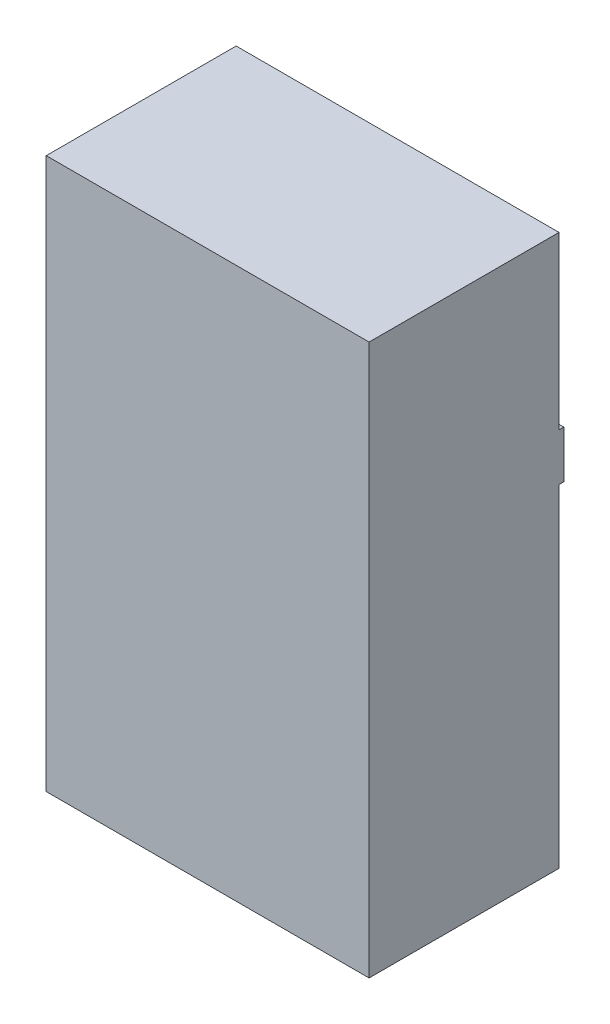
from build123d import *

# Parameters (mm, degrees)
SKETCH1_W           = 34
SKETCH1_H           = 58
BOSS_EXTRUDE1_DEPTH = 20
CUT_EXTRUDE1_DEPTH  = 5
SKETCH3_W           = 34
SKETCH3_H           = 5
BOSS_EXTRUDE2_DEPTH = 0.5


with BuildPart() as part:
    # Sketch1 → Boss-Extrude1 (new body)
    with BuildSketch(Plane.XY):
        with Locations((17, 29)):
            Rectangle(SKETCH1_W, SKETCH1_H)
    extrude(amount=BOSS_EXTRUDE1_DEPTH)

    # Sketch2 → Cut-Extrude1 (cut)
    with BuildSketch(Plane.XZ):
        Polygon((10.390351515, 13.754782864), (11.113909207, 13.754782864), (10.625928438, 10.254782864), (10.309722508, 10.254782864), (10.753532604, 13.4406803), (10.264850713, 13.4406803), align=None)
        with BuildLine():
            Line((12.643055841, 12.722731582), (12.328953277, 12.722731582))
            add(Edge.make_bspline(
                [(12.328953277, 12.722731582), (12.332011924, 12.766042879), (12.337989787, 12.850691115), (12.358167334, 12.973391915), (12.38473027, 13.089111099), (12.421716538, 13.196550853), (12.465427205, 13.297118572), (12.519464545, 13.389163263), (12.580321699, 13.474701699), (12.649982028, 13.551793987), (12.726424632, 13.620540594), (12.808860156, 13.680550874), (12.89686882, 13.731071088), (12.990250158, 13.772981842), (13.089302552, 13.804913995), (13.193463165, 13.828253888), (13.303171395, 13.841506096), (13.37803021, 13.843503065), (13.416393181, 13.844526454)],
                knots=[0, 0, 0, 0, 0.000130192, 0.000254449, 0.000372639, 0.000485937, 0.000594855, 0.00070104, 0.000805528, 0.000909287, 0.001012056, 0.00111345, 0.001214589, 0.001315961, 0.001419947, 0.001526261, 0.001635748, 0.001750837, 0.001750837, 0.001750837, 0.001750837], degree=3))
            add(Edge.make_bspline(
                [(13.416393181, 13.844526454), (13.448906153, 13.843648264), (13.512984399, 13.841917481), (13.60708216, 13.830350128), (13.696762583, 13.808643874), (13.782595889, 13.780482818), (13.863701387, 13.742473226), (13.941565938, 13.697869564), (14.014307414, 13.643265009), (14.082803929, 13.582003961), (14.144738145, 13.514528381), (14.198867312, 13.442495662), (14.246182958, 13.367304996), (14.282695193, 13.286764028), (14.312886758, 13.203263703), (14.332671859, 13.115378808), (14.345953396, 13.023918959), (14.347431482, 12.961395984), (14.348184047, 12.929562512)],
                knots=[0, 0, 0, 0, 9.7547e-05, 0.00019225, 0.000283743, 0.000373981, 0.000462761, 0.000551988, 0.000642715, 0.000735061, 0.000827359, 0.000916963, 0.001005106, 0.00109325, 0.001181728, 0.001271013, 0.001363028, 0.001458473, 0.001458473, 0.001458473, 0.001458473], degree=3))
            add(Edge.make_bspline(
                [(14.348184047, 12.929562512), (14.346613841, 12.884331868), (14.343455892, 12.793365368), (14.315970845, 12.657801515), (14.272912565, 12.523039023), (14.22238461, 12.410326163), (14.167104056, 12.315527957), (14.111540247, 12.232493322), (14.041785515, 12.138659995), (13.957720144, 12.0341532), (13.860296079, 11.918137768), (13.749619382, 11.790224009), (13.623738516, 11.652376545), (13.53453459, 11.557355245), (13.487907604, 11.507687512)],
                knots=[0, 0, 0, 0, 0.000135578, 0.00027267, 0.000413248, 0.000559472, 0.000642088, 0.000742233, 0.000859043, 0.000992739, 0.001144539, 0.00131352, 0.001500142, 0.001704517, 0.001704517, 0.001704517, 0.001704517], degree=3))
            Line((13.487907604, 11.507687512), (12.624826675, 10.568885428))
            Line((12.624826675, 10.568885428), (14.168696867, 10.568885428))
            Line((14.168696867, 10.568885428), (14.128732925, 10.254782864))
            Line((14.128732925, 10.254782864), (11.925107124, 10.254782864))
            Line((11.925107124, 10.254782864), (13.098083886, 11.530123409))
            add(Edge.make_bspline(
                [(13.098083886, 11.530123409), (13.125448976, 11.560018602), (13.178841591, 11.618347756), (13.256567902, 11.703972762), (13.330537387, 11.78501513), (13.398946138, 11.863291923), (13.464227047, 11.936634642), (13.525390682, 12.00613654), (13.582039019, 12.071737586), (13.634127663, 12.133895929), (13.682297266, 12.191832911), (13.726593673, 12.245537403), (13.765930846, 12.295866761), (13.801727361, 12.341532729), (13.832599938, 12.384170538), (13.860081837, 12.422097962), (13.882372259, 12.456878075), (13.918860652, 12.513997939), (13.960546521, 12.598318519), (14.003136833, 12.710319869), (14.028741496, 12.821844905), (14.032325457, 12.896022412), (14.034081483, 12.932366999)],
                knots=[0, 0, 0, 0, 0.000121586, 0.000237228, 0.000346928, 0.000450744, 0.000549086, 0.000641491, 0.000728489, 0.000809103, 0.000884779, 0.000954533, 0.001017933, 0.001076412, 0.001128579, 0.001175851, 0.001216883, 0.001252482, 0.00137916, 0.001498066, 0.001611529, 0.001720528, 0.001720528, 0.001720528, 0.001720528], degree=3))
            add(Edge.make_bspline(
                [(14.034081483, 12.932366999), (14.033552936, 12.952960299), (14.032515271, 12.993389929), (14.024004689, 13.052916944), (14.009216133, 13.109748589), (13.988695048, 13.164246235), (13.962526126, 13.216341743), (13.931035635, 13.266488171), (13.892814102, 13.313443105), (13.849424769, 13.357365869), (13.80203737, 13.39767965), (13.751676031, 13.434102149), (13.697061627, 13.463168233), (13.640255282, 13.488124684), (13.579986502, 13.506860428), (13.517004194, 13.52121577), (13.450459254, 13.528660411), (13.405191016, 13.529827151), (13.382038213, 13.53042389)],
                knots=[0, 0, 0, 0, 6.1762e-05, 0.000121255, 0.000179923, 0.000237611, 0.000295618, 0.000354554, 0.000414887, 0.00047686, 0.000539524, 0.000601385, 0.000662881, 0.000724746, 0.000787276, 0.000851916, 0.000918272, 0.000987739, 0.000987739, 0.000987739, 0.000987739], degree=3))
            add(Edge.make_bspline(
                [(13.382038213, 13.53042389), (13.35629539, 13.529744602), (13.306019695, 13.528417954), (13.232347168, 13.51818883), (13.1619958, 13.502394102), (13.094914362, 13.479192584), (13.031851256, 13.448609106), (12.971519136, 13.412907362), (12.9151958, 13.369706972), (12.862892192, 13.320054233), (12.814931266, 13.264570759), (12.772956248, 13.203265323), (12.736027195, 13.136726994), (12.705375672, 13.064565023), (12.680858537, 12.986781375), (12.662135085, 12.903752889), (12.648444231, 12.815208051), (12.644883472, 12.754097698), (12.643055841, 12.722731582)],
                knots=[0, 0, 0, 0, 7.7203e-05, 0.000150777, 0.00022272, 0.000293231, 0.000363164, 0.000432664, 0.000503199, 0.000575608, 0.00064869, 0.000722787, 0.000798104, 0.000876633, 0.000957566, 0.001042437, 0.001131777, 0.001225988, 0.001225988, 0.001225988, 0.001225988], degree=3))
        make_face()
        with BuildLine():
            add(Edge.make_bspline(
                [(16.194237733, 13.844526454), (16.22679258, 13.843438163), (16.290907144, 13.841294847), (16.384817404, 13.824627884), (16.474846903, 13.797968941), (16.560625859, 13.760003033), (16.641992457, 13.710522767), (16.720308511, 13.651910723), (16.793139489, 13.580595994), (16.862565721, 13.500420549), (16.925779132, 13.409987219), (16.980318657, 13.309574436), (17.027652687, 13.200667729), (17.065138701, 13.082134966), (17.094426865, 12.955032471), (17.115266016, 12.818882238), (17.127969662, 12.673896166), (17.129466894, 12.574120477), (17.130235329, 12.522911871)],
                knots=[0, 0, 0, 0, 9.7617e-05, 0.00019225, 0.000285193, 0.000378735, 0.000472763, 0.000570361, 0.000671517, 0.000777907, 0.000888188, 0.001001779, 0.001120171, 0.001243895, 0.001374169, 0.001511111, 0.001656791, 0.001810394, 0.001810394, 0.001810394, 0.001810394], degree=3))
            add(Edge.make_bspline(
                [(17.130235329, 12.522911871), (17.129605829, 12.463298015), (17.128363109, 12.345611973), (17.117173997, 12.171405417), (17.101122729, 12.001682782), (17.076076243, 11.836874867), (17.04550083, 11.676528452), (17.007664064, 11.52090074), (16.962874658, 11.36991462), (16.911046255, 11.224801189), (16.854716569, 11.087431321), (16.796014434, 10.958851878), (16.733479046, 10.841411265), (16.669455014, 10.733258938), (16.600895439, 10.636664569), (16.531475276, 10.548792799), (16.457204507, 10.47308429), (16.381338111, 10.406573982), (16.302984776, 10.349822268), (16.22369347, 10.300296448), (16.142754126, 10.2591953), (16.061187818, 10.223891793), (15.977298484, 10.19834121), (15.892451055, 10.179506008), (15.806207536, 10.166622423), (15.748137069, 10.165569706), (15.718877156, 10.165039275)],
                knots=[0, 0, 0, 0, 0.00017882, 0.000353016, 0.00052352, 0.000690101, 0.000852906, 0.001013094, 0.001170372, 0.00132516, 0.001475149, 0.001615688, 0.001748985, 0.001874156, 0.001992421, 0.002104109, 0.002209718, 0.002310103, 0.002406446, 0.002499642, 0.002590263, 0.002678552, 0.002765925, 0.002852847, 0.002939211, 0.003026921, 0.003026921, 0.003026921, 0.003026921], degree=3))
            add(Edge.make_bspline(
                [(15.718877156, 10.165039275), (15.675730879, 10.166756436), (15.5911539, 10.170122481), (15.46837972, 10.197655498), (15.353442587, 10.242162018), (15.264517318, 10.293801549), (15.198714131, 10.344022462), (15.151326643, 10.386207699), (15.107300208, 10.433577884), (15.065196197, 10.484882808), (15.024916391, 10.540318964), (14.987923098, 10.601048502), (14.952890656, 10.666043225), (14.920633099, 10.735822624), (14.890808694, 10.810224784), (14.865843371, 10.890220015), (14.844893513, 10.97550989), (14.827556416, 11.065863361), (14.813421932, 11.161272118), (14.80372262, 11.261891103), (14.798226296, 11.367868375), (14.797350782, 11.440373385), (14.796901995, 11.477539275)],
                knots=[0, 0, 0, 0, 0.000129328, 0.000253514, 0.000375382, 0.000497918, 0.000560459, 0.000623517, 0.000687998, 0.000754249, 0.00082255, 0.000893377, 0.000967408, 0.001043946, 0.001123886, 0.001207705, 0.001295109, 0.001387236, 0.001483614, 0.001584354, 0.001690372, 0.00180187, 0.00180187, 0.00180187, 0.00180187], degree=3))
            add(Edge.make_bspline(
                [(14.796901995, 11.477539275), (14.79759839, 11.539485458), (14.798968414, 11.661352745), (14.809093343, 11.841194686), (14.824841716, 12.015031858), (14.84780652, 12.182824488), (14.878412066, 12.344301124), (14.913697827, 12.500332072), (14.956343306, 12.650427767), (15.006199694, 12.793641809), (15.060492311, 12.928776473), (15.11811316, 13.054973573), (15.178642732, 13.171401309), (15.243214832, 13.277398651), (15.310565797, 13.373495163), (15.381513666, 13.459165592), (15.455194139, 13.535591426), (15.532519945, 13.601636637), (15.61234644, 13.658060499), (15.692013761, 13.708692414), (15.773873964, 13.749725156), (15.85590411, 13.784489901), (15.939159511, 13.811472053), (16.023486332, 13.82998807), (16.108538297, 13.84289253), (16.165677956, 13.843981941), (16.194237733, 13.844526454)],
                knots=[0, 0, 0, 0, 0.00018583, 0.000365586, 0.00054021, 0.000709368, 0.00087342, 0.001033123, 0.00118914, 0.001341246, 0.001487846, 0.001625889, 0.001757291, 0.001881262, 0.001997978, 0.002109023, 0.002214632, 0.002316079, 0.002413558, 0.00250772, 0.002598966, 0.0026879, 0.002774817, 0.002861055, 0.002946724, 0.003032332, 0.003032332, 0.003032332, 0.003032332], degree=3))
        make_face()
        with BuildLine():
            add(Edge.make_bspline(
                [(16.170399591, 13.53042389), (16.151425115, 13.529703819), (16.113231413, 13.528254387), (16.055720665, 13.517715421), (15.997349907, 13.501775947), (15.938061749, 13.478151586), (15.878282007, 13.447929513), (15.817252732, 13.411798218), (15.755704036, 13.368846929), (15.693257646, 13.319418973), (15.632089219, 13.261663881), (15.573187301, 13.195560319), (15.516854379, 13.120798705), (15.463768715, 13.036798581), (15.412506566, 12.944198135), (15.364452141, 12.842411331), (15.318933546, 12.732164326), (15.276374026, 12.6137879), (15.237027962, 12.488362722), (15.203679435, 12.356016178), (15.17471115, 12.21807198), (15.152202779, 12.073819227), (15.132590445, 11.924065654), (15.12072041, 11.768188852), (15.11265247, 11.606631182), (15.111560665, 11.496947639), (15.111004559, 11.441080941)],
                knots=[0, 0, 0, 0, 5.6899e-05, 0.000114532, 0.000174918, 0.000238194, 0.000305607, 0.000375709, 0.000450782, 0.000530605, 0.000614426, 0.000702812, 0.000795922, 0.000894919, 0.001000677, 0.001113263, 0.0012324, 0.001358372, 0.00149054, 0.00162658, 0.00176766, 0.001913241, 0.00206447, 0.00222063, 0.002382072, 0.002549664, 0.002549664, 0.002549664, 0.002549664], degree=3))
            add(Edge.make_bspline(
                [(15.111004559, 11.441080941), (15.111469882, 11.401563813), (15.112368625, 11.325238736), (15.121315164, 11.214599766), (15.133684431, 11.111596883), (15.153696789, 11.016846753), (15.177792289, 10.929558383), (15.20868335, 10.850580621), (15.244325078, 10.778873991), (15.285899706, 10.715635091), (15.331519991, 10.66016609), (15.380195111, 10.612007183), (15.431548681, 10.571265811), (15.485053864, 10.537002164), (15.541651743, 10.510760322), (15.601151447, 10.492716147), (15.663021426, 10.480915009), (15.705267993, 10.479736581), (15.726589495, 10.479141839)],
                knots=[0, 0, 0, 0, 0.000118523, 0.00022892, 0.000332842, 0.000429508, 0.000519169, 0.00060419, 0.000683519, 0.000758971, 0.000830698, 0.00089862, 0.00096399, 0.001027013, 0.001088811, 0.001150462, 0.001213172, 0.001277071, 0.001277071, 0.001277071, 0.001277071], degree=3))
            add(Edge.make_bspline(
                [(15.726589495, 10.479141839), (15.748837782, 10.479768689), (15.793385922, 10.481023843), (15.859745617, 10.492744733), (15.925185875, 10.511905833), (15.98997704, 10.538034091), (16.05425105, 10.571403338), (16.118084334, 10.611912566), (16.180426777, 10.661139244), (16.242820616, 10.716036145), (16.303095616, 10.778612706), (16.360453466, 10.848020943), (16.414530677, 10.92396799), (16.464886594, 11.006433723), (16.512691449, 11.094765257), (16.556737309, 11.189657165), (16.597595775, 11.291028772), (16.621559861, 11.361497312), (16.633841098, 11.39761139)],
                knots=[0, 0, 0, 0, 6.6699e-05, 0.000133552, 0.000201449, 0.000270973, 0.000342782, 0.000418442, 0.000497398, 0.000580835, 0.000667607, 0.000757736, 0.000850732, 0.000947051, 0.001047436, 0.001151887, 0.00126073, 0.001375149, 0.001375149, 0.001375149, 0.001375149], degree=3))
            add(Edge.make_bspline(
                [(16.633841098, 11.39761139), (16.648493494, 11.444001362), (16.677915517, 11.537152465), (16.714957507, 11.679394988), (16.745358796, 11.824126187), (16.771969405, 11.970821931), (16.790896901, 12.120204892), (16.806124285, 12.271649505), (16.81448476, 12.425593931), (16.815580369, 12.528979148), (16.816132765, 12.58110498)],
                knots=[0, 0, 0, 0, 0.000145931, 0.00029303, 0.000440719, 0.000589532, 0.000740155, 0.000892312, 0.001046088, 0.001202463, 0.001202463, 0.001202463, 0.001202463], degree=3))
            add(Edge.make_bspline(
                [(16.816132765, 12.58110498), (16.815615735, 12.619447404), (16.814615018, 12.693659689), (16.806325895, 12.801417194), (16.791700495, 12.901663827), (16.771452649, 12.994725147), (16.74576626, 13.080439543), (16.714257193, 13.158694278), (16.677038522, 13.229684121), (16.63351841, 13.292638975), (16.585588184, 13.348134454), (16.534944716, 13.396797962), (16.481843766, 13.438726795), (16.42494124, 13.471770191), (16.365513697, 13.498134006), (16.303134013, 13.5169379), (16.237683462, 13.528697553), (16.193119778, 13.529840946), (16.170399591, 13.53042389)],
                knots=[0, 0, 0, 0, 0.000115018, 0.000222619, 0.000323955, 0.00041871, 0.000508094, 0.000592071, 0.000671422, 0.000748046, 0.000821128, 0.000891047, 0.000958504, 0.001023558, 0.001087912, 0.00115312, 0.001218592, 0.001286691, 0.001286691, 0.001286691, 0.001286691], degree=3))
        make_face(mode=Mode.SUBTRACT)
        Polygon((17.713568662, 13.754782864), (18.039590297, 13.754782864), (18.933520585, 10.963616999), (20.543997348, 13.754782864), (20.899466098, 13.754782864), (18.880235329, 10.254782864), (18.835363534, 10.254782864), align=None)
    extrude(amount=-CUT_EXTRUDE1_DEPTH, mode=Mode.SUBTRACT)

    # Sketch3 → Boss-Extrude2 (add)
    with BuildSketch(Plane(origin=(0, 0, 0), x_dir=(-1, 0, 0), z_dir=(0, 0, -1))):
        with Locations((-17, 37.5)):
            Rectangle(SKETCH3_W, SKETCH3_H)
    extrude(amount=BOSS_EXTRUDE2_DEPTH)


solid = part.part
